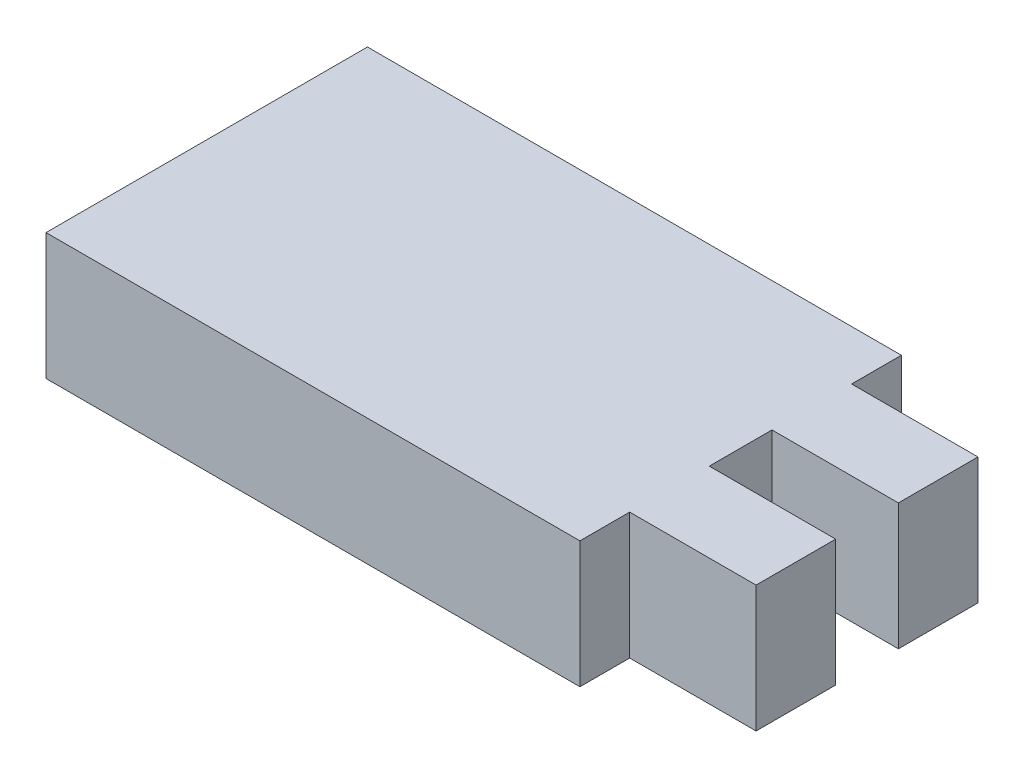
from build123d import *

# Parameters (mm, degrees)
BOSS_EXTRUDE1_DEPTH = 6.35


with BuildPart() as part:
    # Sketch1 → Boss-Extrude1 (new body)
    with BuildSketch(Plane(origin=(0, 0, 0), x_dir=(1, 0, 0), z_dir=(0, 1, 0))):
        Polygon((16.5875, 5.575), (10.2375, 5.575), (10.2375, 8.075), (-16.5875, 8.075), (-16.5875, -8.075), (10.2375, -8.075), (10.2375, -5.575), (16.5875, -5.575), (16.5875, -1.575), (10.2375, -1.575), (10.2375, 1.575), (16.5875, 1.575), align=None)
    extrude(amount=BOSS_EXTRUDE1_DEPTH)


solid = part.part
